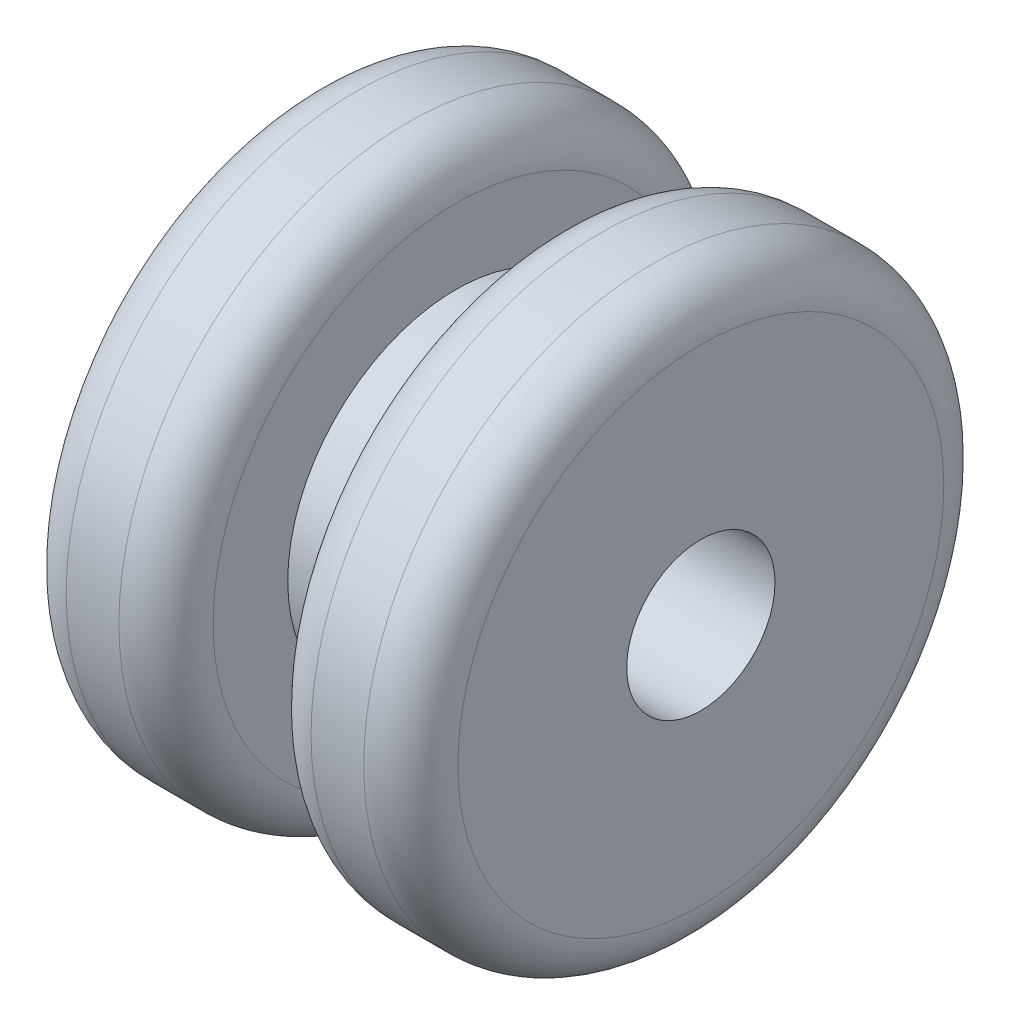
from build123d import *

# Parameters (mm, degrees)
SKETCH1_R           = 9.779
SKETCH1_R_2         = 2.5
BOSS_EXTRUDE1_DEPTH = 6.604
SKETCH2_R           = 11.049
SKETCH2_R_2         = 5.675
CUT_EXTRUDE1_DEPTH  = 1.651
FILLET1_R           = 1.5875


with BuildPart() as part:
    # Sketch1 → Boss-Extrude1 (new body, symmetric)
    with BuildSketch(Plane(origin=(0, 0, 0), x_dir=(0, 0, -1), z_dir=(1, 0, 0))):
        Circle(SKETCH1_R)
        Circle(SKETCH1_R_2, mode=Mode.SUBTRACT)
    extrude(amount=BOSS_EXTRUDE1_DEPTH, both=True)

    # Sketch2 → Cut-Extrude1 (cut, symmetric)
    with BuildSketch(Plane(origin=(0, 0, 0), x_dir=(0, 0, -1), z_dir=(1, 0, 0))):
        Circle(SKETCH2_R)
        Circle(SKETCH2_R_2, mode=Mode.SUBTRACT)
    extrude(amount=CUT_EXTRUDE1_DEPTH, both=True, mode=Mode.SUBTRACT)

    # Fillet1
    fillet1_edges = [part.edges().sort_by_distance(p)[0] for p in [
        (1.651, 0, 9.779),
        (-1.651, 0, 9.779),
        (-6.604, 0, 9.779),
        (6.604, 0, 9.779),
    ]]
    fillet(fillet1_edges, radius=FILLET1_R)


solid = part.part
